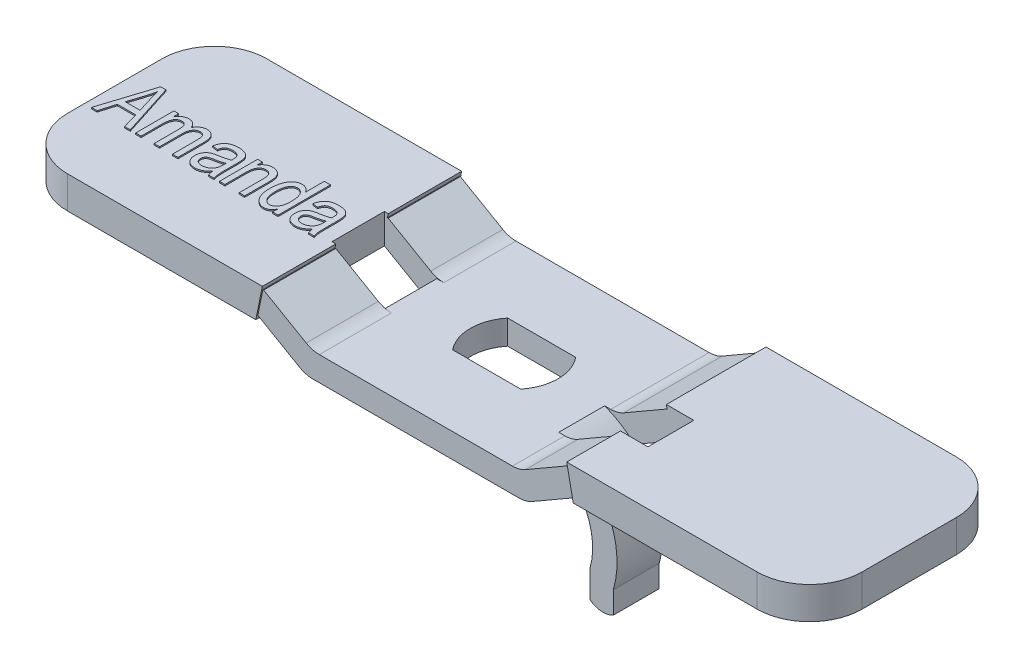
from build123d import *

# Parameters (mm, degrees)
BOSS_EXTRUDE1_DEPTH = 9.525
FILLET1_R           = 5.08
BOSS_EXTRUDE2_DEPTH = 9.652
SKETCH2_W           = 5.08
SKETCH2_H           = 5.08
SKETCH2_W_2         = 8.636
SKETCH2_H_2         = 4.445
CUT_EXTRUDE1_DEPTH  = 19.05
FILLET2_R           = 5.08
BOSS_EXTRUDE3_DEPTH = 4.445
FILLET3_R           = 2.54
BOSS_EXTRUDE4_DEPTH = 0.127


with BuildPart() as part:
    # Sketch1 → Boss-Extrude1 (new body, symmetric)
    with BuildSketch(Plane.XY):
        Polygon((15.375367685, 2.7178), (37.888728983, 2.7178), (37.888728983, 5.08), (14.742418102, 5.08), (10.035050418, 2.3622), (-10.035050418, 2.3622), (-14.742418102, 5.08), (-38.311271017, 5.08), (-38.311271017, 2.7178), (-15.375367685, 2.7178), (-10.668, 0), (10.668, 0), align=None)
    extrude(amount=BOSS_EXTRUDE1_DEPTH, both=True)

    # Fillet1
    fillet1_edges = [part.edges().sort_by_distance(p)[0] for p in [
        (37.888728983, 3.8989, 9.525),
        (-38.311271017, 3.8989, -9.525),
        (37.888728983, 3.8989, -9.525),
        (-38.311271017, 3.8989, 9.525),
    ]]
    fillet(fillet1_edges, radius=FILLET1_R)

    # Sketch3 → Boss-Extrude2 (add, symmetric)
    with BuildSketch(Plane.XY):
        Polygon((-38.692271017, 5.461), (-14.742418102, 5.461), (-15.375367685, 2.3368), (-38.692271017, 2.3368), align=None)
        Polygon((15.375367685, 2.3368), (38.269728983, 2.3368), (38.269728983, 5.461), (14.742418102, 5.461), align=None)
    extrude(amount=BOSS_EXTRUDE2_DEPTH, both=True)

    # Sketch2 → Cut-Extrude1 (cut)
    with BuildSketch(Plane(origin=(0, 0, 0), x_dir=(1, 0, 0), z_dir=(0, 1, 0))):
        with Locations((-12.575050418, 0)):
            Rectangle(SKETCH2_W, SKETCH2_H)
        with Locations((13.083050418, -2.2225)):
            Rectangle(SKETCH2_W_2, SKETCH2_H_2)
        with BuildLine():
            Line((3.298481202, -2.667), (-3.298481202, -2.667))
            ThreePointArc((-3.298481202, -2.667), (-4.2418, 0), (-3.298481202, 2.667))
            Line((-3.298481202, 2.667), (3.298481202, 2.667))
            ThreePointArc((3.298481202, 2.667), (4.2418, 0), (3.298481202, -2.667))
        make_face()
    extrude(amount=CUT_EXTRUDE1_DEPTH, mode=Mode.SUBTRACT)

    # Fillet2
    fillet2_edges = [part.edges().sort_by_distance(p)[0] for p in [
        (38.269728983, 3.8989, -9.652),
        (38.269728983, 3.8989, 9.652),
        (-38.692271017, 3.8989, -9.652),
        (-38.692271017, 3.8989, 9.652),
    ]]
    fillet(fillet2_edges, radius=FILLET2_R)

    # Sketch4 → Boss-Extrude3 (add)
    with BuildSketch(Plane.XY):
        with BuildLine():
            Line((8.765050418, 2.3622), (8.765050418, 0))
            ThreePointArc((8.765050418, 0), (11.584407716, -3.265765814), (11.774115705, -7.575987711))
            Line((11.774115705, -7.575987711), (11.774115705, -10.161057305))
            ThreePointArc((11.774115705, -10.161057305), (12.886519507, -10.585606292), (14.051112182, -10.3378))
            Line((14.051112182, -10.3378), (14.051112182, -8.204697409))
            ThreePointArc((14.051112182, -8.204697409), (13.496081615, -1.876732211), (8.765050418, 2.3622))
        make_face()
    extrude(amount=BOSS_EXTRUDE3_DEPTH)

    # Fillet3
    fillet3_edges = [part.edges().sort_by_distance(p)[0] for p in [
        (10.668, 0, 6.985),
        (10.668, 0, -4.7625),
        (-10.668, 0, 6.0325),
        (-10.035050418, 2.3622, -6.0325),
        (10.035050418, 2.3622, 6.985),
        (10.035050418, 2.3622, -4.7625),
        (-10.035050418, 2.3622, 6.0325),
    ]]
    fillet(fillet3_edges, radius=FILLET3_R)

    # Sketch5 → Boss-Extrude4 (add)
    with BuildSketch(Plane(origin=(0, 5.461, 0), x_dir=(1, 0, 0), z_dir=(0, 1, 0))):
        Polygon((-37.905243778, -3.048), (-36.282695077, 2.032), (-35.768303843, 2.032), (-34.144724298, -3.048), (-34.693133389, -3.048), (-35.13742722, -1.530597403), (-36.912540856, -1.530597403), (-37.355803843, -3.048), align=None)
        with BuildLine():
            Line((-36.739359038, -0.936831169), (-35.311639882, -0.936831169))
            Line((-35.311639882, -0.936831169), (-35.736347674, 0.458931818))
            add(Edge.make_bspline(
                [(-35.736347674, 0.458931818), (-35.752236099, 0.511136876), (-35.783255933, 0.613059641), (-35.827182846, 0.762305939), (-35.869342701, 0.903863262), (-35.905355341, 1.038719049), (-35.941165615, 1.165118694), (-35.972049539, 1.284468818), (-35.999773008, 1.396177097), (-36.016803166, 1.468455951), (-36.024984038, 1.503176948)],
                knots=[0, 0, 0, 0, 0.000163706, 0.000319613, 0.000466735, 0.000606782, 0.000738331, 0.000860845, 0.000976603, 0.001083617, 0.001083617, 0.001083617, 0.001083617], degree=3))
            add(Edge.make_bspline(
                [(-36.024984038, 1.503176948), (-36.039835852, 1.422302291), (-36.069519751, 1.260660411), (-36.12516105, 1.019864869), (-36.187063684, 0.779503851), (-36.236335898, 0.620929172), (-36.26104735, 0.541399351)],
                knots=[0, 0, 0, 0, 0.00024665, 0.000492972, 0.000741253, 0.000991058, 0.000991058, 0.000991058, 0.000991058], degree=3))
            Line((-36.26104735, 0.541399351), (-36.739359038, -0.936831169))
        make_face(mode=Mode.SUBTRACT)
        with BuildLine():
            Line((-33.61693209, -3.048), (-33.61693209, 0.646545455))
            Line((-33.61693209, 0.646545455), (-33.155113908, 0.646545455))
            Line((-33.155113908, 0.646545455), (-33.155113908, 0.125969156))
            add(Edge.make_bspline(
                [(-33.155113908, 0.125969156), (-33.129105702, 0.171044772), (-33.078259634, 0.259167647), (-32.984275697, 0.376165428), (-32.880376363, 0.477269279), (-32.76670311, 0.562434272), (-32.64419807, 0.629636863), (-32.51490498, 0.677154815), (-32.380309915, 0.707695375), (-32.288338634, 0.710898281), (-32.241785986, 0.712519481)],
                knots=[0, 0, 0, 0, 0.000155934, 0.000304851, 0.000448464, 0.000589896, 0.000729674, 0.00086601, 0.001002086, 0.001141558, 0.001141558, 0.001141558, 0.001141558], degree=3))
            add(Edge.make_bspline(
                [(-32.241785986, 0.712519481), (-32.190426095, 0.710627182), (-32.091241039, 0.706972818), (-31.948525295, 0.676302597), (-31.818051742, 0.626104499), (-31.70142339, 0.55357165), (-31.597990027, 0.463205), (-31.510597164, 0.353221481), (-31.439470499, 0.224483046), (-31.407070101, 0.129663896), (-31.390308713, 0.080612013)],
                knots=[0, 0, 0, 0, 0.000153941, 0.000297288, 0.00043569, 0.000571296, 0.000707156, 0.00084577, 0.00099065, 0.001145928, 0.001145928, 0.001145928, 0.001145928], degree=3))
            add(Edge.make_bspline(
                [(-31.390308713, 0.080612013), (-31.360014596, 0.13073863), (-31.301582224, 0.227424636), (-31.201241271, 0.356953549), (-31.094454655, 0.466847023), (-30.980255747, 0.55676612), (-30.858884972, 0.626204561), (-30.731416497, 0.677018367), (-30.596840897, 0.70621142), (-30.504949649, 0.71039922), (-30.458425596, 0.712519481)],
                knots=[0, 0, 0, 0, 0.000175598, 0.000338699, 0.000490321, 0.000634256, 0.00077324, 0.000908387, 0.001044462, 0.001184008, 0.001184008, 0.001184008, 0.001184008], degree=3))
            add(Edge.make_bspline(
                [(-30.458425596, 0.712519481), (-30.423318685, 0.71195128), (-30.354505755, 0.710837551), (-30.254479256, 0.695561566), (-30.159784894, 0.673107858), (-30.070609794, 0.641838298), (-29.988593819, 0.598008296), (-29.910727007, 0.548097879), (-29.839251646, 0.487619294), (-29.773723509, 0.417898488), (-29.714711531, 0.338319079), (-29.66375548, 0.247611044), (-29.622267259, 0.145401317), (-29.585558042, 0.033409941), (-29.559741963, -0.090452669), (-29.53995959, -0.224660825), (-29.529014581, -0.370374537), (-29.527386163, -0.471216441), (-29.526542479, -0.523462662)],
                knots=[0, 0, 0, 0, 0.000105227, 0.000206255, 0.000302764, 0.000397, 0.000488751, 0.000581103, 0.000674022, 0.000768826, 0.000867582, 0.000970512, 0.00108002, 0.001198032, 0.001323596, 0.00145903, 0.001604821, 0.001761563, 0.001761563, 0.001761563, 0.001761563], degree=3))
            Line((-29.526542479, -0.523462662), (-29.526542479, -3.048))
            Line((-29.526542479, -3.048), (-30.054334687, -3.048))
            Line((-30.054334687, -3.048), (-30.054334687, -0.722415584))
            add(Edge.make_bspline(
                [(-30.054334687, -0.722415584), (-30.054579593, -0.661223159), (-30.055031405, -0.548332954), (-30.066687032, -0.393509892), (-30.082422932, -0.267005804), (-30.107351812, -0.165845484), (-30.140532221, -0.083657025), (-30.181700634, -0.013646077), (-30.23311364, 0.04590908), (-30.292367263, 0.095268339), (-30.35655009, 0.135837826), (-30.426485605, 0.16377399), (-30.499715265, 0.182367995), (-30.550399599, 0.183936719), (-30.57594183, 0.184727273)],
                knots=[0, 0, 0, 0, 0.000183516, 0.000338558, 0.000465536, 0.000565544, 0.000650155, 0.000730594, 0.000808079, 0.000884896, 0.000961276, 0.001034784, 0.001110043, 0.001186499, 0.001186499, 0.001186499, 0.001186499], degree=3))
            add(Edge.make_bspline(
                [(-30.57594183, 0.184727273), (-30.602109688, 0.183967741), (-30.65371459, 0.182469889), (-30.72943055, 0.169590906), (-30.801624099, 0.149498916), (-30.869833741, 0.119614581), (-30.934347589, 0.082977712), (-30.995421017, 0.037784347), (-31.051807036, -0.016439202), (-31.105786891, -0.077727804), (-31.153228667, -0.149058535), (-31.196109064, -0.228699461), (-31.23053878, -0.318577528), (-31.258120613, -0.417797325), (-31.280596789, -0.525565966), (-31.297246619, -0.642939506), (-31.306125255, -0.769694217), (-31.307256353, -0.857443167), (-31.307841181, -0.902813312)],
                knots=[0, 0, 0, 0, 7.8453e-05, 0.000154714, 0.000229761, 0.000302718, 0.000377516, 0.000451944, 0.000529969, 0.000611816, 0.000696446, 0.000786372, 0.00088266, 0.000984469, 0.001095058, 0.001212705, 0.001339838, 0.001475945, 0.001475945, 0.001475945, 0.001475945], degree=3))
            Line((-31.307841181, -0.902813312), (-31.307841181, -3.048))
            Line((-31.307841181, -3.048), (-31.835633389, -3.048))
            Line((-31.835633389, -3.048), (-31.835633389, -0.649225649))
            add(Edge.make_bspline(
                [(-31.835633389, -0.649225649), (-31.83603731, -0.612454267), (-31.836815574, -0.541604292), (-31.842497715, -0.439333436), (-31.854312137, -0.345883479), (-31.868030271, -0.260249401), (-31.887539642, -0.183404411), (-31.910855301, -0.114876659), (-31.939086428, -0.055168747), (-31.980510564, 0.012403491), (-32.043668244, 0.081501021), (-32.133850325, 0.142647121), (-32.238440879, 0.179191148), (-32.312619838, 0.18283778), (-32.351055466, 0.184727273)],
                knots=[0, 0, 0, 0, 0.00011032, 0.00021256, 0.00030705, 0.000392802, 0.000472558, 0.000544607, 0.000609623, 0.000670268, 0.000781909, 0.000887408, 0.000994338, 0.001109323, 0.001109323, 0.001109323, 0.001109323], degree=3))
            add(Edge.make_bspline(
                [(-32.351055466, 0.184727273), (-32.378946978, 0.184063015), (-32.433356079, 0.182767219), (-32.512668272, 0.168888645), (-32.587124571, 0.146335507), (-32.657044033, 0.114544575), (-32.723897185, 0.075941647), (-32.784481905, 0.025294907), (-32.84145081, -0.032436781), (-32.89420082, -0.099671922), (-32.940996374, -0.179163731), (-32.980781768, -0.272839361), (-33.014447204, -0.38063453), (-33.042015964, -0.503039945), (-33.063097036, -0.639802389), (-33.078347288, -0.791195265), (-33.087538569, -0.956990142), (-33.088591731, -1.072546637), (-33.089139882, -1.132691558)],
                knots=[0, 0, 0, 0, 8.36e-05, 0.000163082, 0.00024069, 0.000316364, 0.000393091, 0.000471497, 0.00055241, 0.00063613, 0.000727178, 0.00082829, 0.000940766, 0.001065549, 0.00120435, 0.001355645, 0.00152187, 0.001702294, 0.001702294, 0.001702294, 0.001702294], degree=3))
            Line((-33.089139882, -1.132691558), (-33.089139882, -3.048))
            Line((-33.089139882, -3.048), (-33.61693209, -3.048))
        make_face()
        with BuildLine():
            add(Edge.make_bspline(
                [(-26.689659363, -2.538762987), (-26.732935088, -2.584154506), (-26.817068903, -2.672401706), (-26.951834425, -2.789493335), (-27.089278233, -2.889210566), (-27.229581229, -2.971333075), (-27.37286375, -3.034638826), (-27.518215515, -3.080784808), (-27.666882841, -3.108394635), (-27.767122658, -3.112110268), (-27.817402869, -3.113974026)],
                knots=[0, 0, 0, 0, 0.000188066, 0.000365626, 0.000534713, 0.000696844, 0.000852378, 0.001003656, 0.001153484, 0.001304273, 0.001304273, 0.001304273, 0.001304273], degree=3))
            add(Edge.make_bspline(
                [(-27.817402869, -3.113974026), (-27.856279769, -3.113337128), (-27.9322168, -3.112093095), (-28.043144043, -3.097839946), (-28.148342792, -3.077184624), (-28.247116387, -3.045398488), (-28.340480754, -3.00674966), (-28.42723735, -2.95773832), (-28.508523209, -2.900938285), (-28.582327772, -2.834703488), (-28.649574589, -2.761937459), (-28.707472871, -2.681700037), (-28.757367123, -2.595936562), (-28.797744113, -2.503568712), (-28.828221913, -2.405223529), (-28.851326871, -2.301187667), (-28.8647225, -2.191034793), (-28.866100032, -2.115465696), (-28.86680222, -2.076944805)],
                knots=[0, 0, 0, 0, 0.000116558, 0.00022767, 0.000335021, 0.000437718, 0.000538425, 0.000637649, 0.000736034, 0.000835338, 0.000934567, 0.001032714, 0.001131551, 0.001231718, 0.001334415, 0.001439965, 0.001551076, 0.001666605, 0.001666605, 0.001666605, 0.001666605], degree=3))
            add(Edge.make_bspline(
                [(-28.86680222, -2.076944805), (-28.865436381, -2.025618963), (-28.862777788, -1.925713666), (-28.835712256, -1.78072241), (-28.79408187, -1.644465587), (-28.733592487, -1.518170599), (-28.658772253, -1.403339607), (-28.570987936, -1.300445065), (-28.470291832, -1.211459128), (-28.375947682, -1.148055151), (-28.292093843, -1.104081559), (-28.220951506, -1.073546591), (-28.142444528, -1.044834427), (-28.056616461, -1.017677445), (-27.962785964, -0.994621031), (-27.861398211, -0.9728324), (-27.752384745, -0.953372641), (-27.676898419, -0.942452934), (-27.638035986, -0.936831169)],
                knots=[0, 0, 0, 0, 0.000153817, 0.000299403, 0.000440903, 0.000580155, 0.000717969, 0.000851023, 0.000984656, 0.001119889, 0.001190898, 0.001268458, 0.00135195, 0.00144161, 0.001538367, 0.001641683, 0.001752694, 0.00187049, 0.00187049, 0.00187049, 0.00187049], degree=3))
            add(Edge.make_bspline(
                [(-27.638035986, -0.936831169), (-27.585745319, -0.927878137), (-27.484696117, -0.910576833), (-27.339449384, -0.880275938), (-27.204535355, -0.849694415), (-27.08098856, -0.816614824), (-26.967222381, -0.783928019), (-26.864856971, -0.748875624), (-26.772396979, -0.713705109), (-26.716282178, -0.686053806), (-26.689659363, -0.672935065)],
                knots=[0, 0, 0, 0, 0.000159141, 0.000307533, 0.000445064, 0.000574085, 0.000691189, 0.000800069, 0.000898653, 0.000987647, 0.000987647, 0.000987647, 0.000987647], degree=3))
            Line((-26.689659363, -0.672935065), (-26.689659363, -0.522431818))
            add(Edge.make_bspline(
                [(-26.689659363, -0.522431818), (-26.689879796, -0.493887582), (-26.690302868, -0.439103441), (-26.698361258, -0.360394835), (-26.707850331, -0.28788318), (-26.722931571, -0.221769193), (-26.744155325, -0.162817288), (-26.767403267, -0.109409506), (-26.795951111, -0.062603806), (-26.819494203, -0.036252668), (-26.830885012, -0.023503247)],
                knots=[0, 0, 0, 0, 8.5585e-05, 0.000164261, 0.000237152, 0.000304914, 0.000367184, 0.000424856, 0.000479491, 0.000530702, 0.000530702, 0.000530702, 0.000530702], degree=3))
            add(Edge.make_bspline(
                [(-26.830885012, -0.023503247), (-26.847986806, -0.006858294), (-26.88260318, 0.026833372), (-26.943348697, 0.068957812), (-27.010572585, 0.104911901), (-27.084047374, 0.134975886), (-27.164244208, 0.157833215), (-27.251421671, 0.172322678), (-27.344993572, 0.183472061), (-27.409838619, 0.184300815), (-27.44320644, 0.184727273)],
                knots=[0, 0, 0, 0, 7.1493e-05, 0.000144712, 0.000220813, 0.000299873, 0.000382424, 0.000470385, 0.000564757, 0.000664796, 0.000664796, 0.000664796, 0.000664796], degree=3))
            add(Edge.make_bspline(
                [(-27.44320644, 0.184727273), (-27.501760839, 0.183637508), (-27.61133784, 0.181598154), (-27.764206408, 0.154065892), (-27.894810726, 0.112672212), (-27.986987434, 0.060112571), (-28.048111568, 0.007294884), (-28.090214258, -0.038906819), (-28.128361967, -0.093248826), (-28.163414164, -0.15487301), (-28.196560069, -0.22349137), (-28.224801768, -0.300820454), (-28.252173241, -0.384782468), (-28.265935736, -0.444304697), (-28.273035986, -0.475012987)],
                knots=[0, 0, 0, 0, 0.000175437, 0.000328309, 0.000464243, 0.000584821, 0.000643298, 0.000706053, 0.000771841, 0.000842037, 0.000918577, 0.001000138, 0.001088814, 0.001183321, 0.001183321, 0.001183321, 0.001183321], degree=3))
            Line((-28.273035986, -0.475012987), (-28.800828194, -0.409038961))
            add(Edge.make_bspline(
                [(-28.800828194, -0.409038961), (-28.790702715, -0.361841999), (-28.770972446, -0.26987511), (-28.733372686, -0.137500567), (-28.686569177, -0.015341525), (-28.633499895, 0.096921169), (-28.573098354, 0.199032532), (-28.506379368, 0.291734675), (-28.430308226, 0.373009453), (-28.348454451, 0.446380666), (-28.257394715, 0.509899904), (-28.15744808, 0.564420267), (-28.047905593, 0.609437136), (-27.93031606, 0.648202662), (-27.802703393, 0.676033233), (-27.666527299, 0.698216108), (-27.52073551, 0.710217766), (-27.420547539, 0.711737399), (-27.368985661, 0.712519481)],
                knots=[0, 0, 0, 0, 0.000144796, 0.000282146, 0.000412331, 0.000536824, 0.000654214, 0.000767822, 0.000878703, 0.00098751, 0.001097042, 0.001210986, 0.001328344, 0.001451895, 0.001581933, 0.001719715, 0.00186559, 0.002020271, 0.002020271, 0.002020271, 0.002020271], degree=3))
            add(Edge.make_bspline(
                [(-27.368985661, 0.712519481), (-27.328766713, 0.711894976), (-27.250647667, 0.710681973), (-27.136777077, 0.702190372), (-27.02962269, 0.689333864), (-26.928950774, 0.669889567), (-26.835271411, 0.643561792), (-26.747213908, 0.614485712), (-26.666286378, 0.578398799), (-26.570692243, 0.522490169), (-26.465559129, 0.444823614), (-26.35995956, 0.339855924), (-26.282663921, 0.221255039), (-26.240158504, 0.113374394), (-26.21754076, 0.020520352), (-26.201903703, -0.056450126), (-26.189974043, -0.141528287), (-26.179716632, -0.234004451), (-26.171657128, -0.334046261), (-26.165223609, -0.441262635), (-26.162490177, -0.556091474), (-26.162079567, -0.635136762), (-26.161867155, -0.676027597)],
                knots=[0, 0, 0, 0, 0.000120648, 0.000234341, 0.000342383, 0.000444275, 0.000541557, 0.000634138, 0.000722268, 0.000806785, 0.000965949, 0.001113198, 0.001251011, 0.001387496, 0.001458751, 0.001537595, 0.001623025, 0.001716372, 0.001816703, 0.001924089, 0.002038555, 0.002161229, 0.002161229, 0.002161229, 0.002161229], degree=3))
            Line((-26.161867155, -0.676027597), (-26.161867155, -1.506887987))
            add(Edge.make_bspline(
                [(-26.161867155, -1.506887987), (-26.16209037, -1.576299566), (-26.162514711, -1.708254065), (-26.159671789, -1.896201409), (-26.158316703, -2.063904064), (-26.154559523, -2.211636157), (-26.152565378, -2.339184743), (-26.146720828, -2.446345831), (-26.14222873, -2.533363578), (-26.130647477, -2.659949995), (-26.099828071, -2.831767539), (-26.053212491, -2.975952211), (-26.029919103, -3.048)],
                knots=[0, 0, 0, 0, 0.000208231, 0.000395855, 0.000563896, 0.000711339, 0.000839201, 0.000946533, 0.001033277, 0.001100566, 0.001327844, 0.00155484, 0.00155484, 0.00155484, 0.00155484], degree=3))
            Line((-26.029919103, -3.048), (-26.557711311, -3.048))
            add(Edge.make_bspline(
                [(-26.557711311, -3.048), (-26.573958402, -3.010838965), (-26.607202867, -2.934800818), (-26.643391279, -2.811471612), (-26.672748326, -2.678921622), (-26.68392216, -2.586312914), (-26.689659363, -2.538762987)],
                knots=[0, 0, 0, 0, 0.000121561, 0.000248736, 0.000384811, 0.000528409, 0.000528409, 0.000528409, 0.000528409], degree=3))
        make_face()
        with BuildLine():
            add(Edge.make_bspline(
                [(-26.689659363, -1.200727273), (-26.71600177, -1.213689875), (-26.770808367, -1.24065917), (-26.858790368, -1.277746873), (-26.955840065, -1.312776683), (-27.06251933, -1.34504688), (-27.177664401, -1.37860434), (-27.302248341, -1.409071815), (-27.435687137, -1.437930415), (-27.527696444, -1.455540277), (-27.575154492, -1.464623377)],
                knots=[0, 0, 0, 0, 8.8063e-05, 0.00018322, 0.000286263, 0.000397446, 0.000517521, 0.000646029, 0.000782105, 0.000927058, 0.000927058, 0.000927058, 0.000927058], degree=3))
            add(Edge.make_bspline(
                [(-27.575154492, -1.464623377), (-27.62778814, -1.473189057), (-27.724788088, -1.488974977), (-27.857646573, -1.515907959), (-27.964538625, -1.546130041), (-28.049310734, -1.578459353), (-28.116699925, -1.61645288), (-28.17397368, -1.660117272), (-28.224076186, -1.710834757), (-28.26508293, -1.768984702), (-28.298279981, -1.8319636), (-28.322604926, -1.899863251), (-28.335613156, -1.972679396), (-28.337862399, -2.022607009), (-28.339010012, -2.048081169)],
                knots=[0, 0, 0, 0, 0.00015998, 0.000294832, 0.000406411, 0.000492934, 0.000566327, 0.000637664, 0.000708373, 0.000779314, 0.000850323, 0.000921399, 0.000994792, 0.001071248, 0.001071248, 0.001071248, 0.001071248], degree=3))
            add(Edge.make_bspline(
                [(-28.339010012, -2.048081169), (-28.337469715, -2.087212609), (-28.334503804, -2.162561928), (-28.299004164, -2.268792232), (-28.245362745, -2.363718413), (-28.168117685, -2.44396017), (-28.072236454, -2.508401472), (-27.958275753, -2.553328325), (-27.828745065, -2.581678956), (-27.73681482, -2.584631566), (-27.68854735, -2.586181818)],
                knots=[0, 0, 0, 0, 0.000116941, 0.000225174, 0.000332323, 0.000441699, 0.000556062, 0.000676278, 0.000807098, 0.000951714, 0.000951714, 0.000951714, 0.000951714], degree=3))
            add(Edge.make_bspline(
                [(-27.68854735, -2.586181818), (-27.641340715, -2.584755889), (-27.54825841, -2.581944232), (-27.412201777, -2.554832226), (-27.282178119, -2.513074966), (-27.160906013, -2.452775365), (-27.049929297, -2.379498313), (-26.95288152, -2.292881372), (-26.870474605, -2.195304109), (-26.814707582, -2.103744102), (-26.77784258, -2.023481822), (-26.754121134, -1.956173151), (-26.735377923, -1.88245221), (-26.716731432, -1.80303555), (-26.70558532, -1.716325078), (-26.695810433, -1.62356695), (-26.691062972, -1.524116038), (-26.6901379, -1.455692404), (-26.689659363, -1.420297078)],
                knots=[0, 0, 0, 0, 0.000141466, 0.000278944, 0.000414554, 0.000550093, 0.000683897, 0.000812393, 0.000938969, 0.001065729, 0.001132615, 0.001203691, 0.001279456, 0.001360742, 0.001448212, 0.001541451, 0.001640546, 0.001746743, 0.001746743, 0.001746743, 0.001746743], degree=3))
            Line((-26.689659363, -1.420297078), (-26.689659363, -1.200727273))
        make_face(mode=Mode.SUBTRACT)
        with BuildLine():
            Line((-25.502126895, -3.048), (-25.502126895, 0.646545455))
            Line((-25.502126895, 0.646545455), (-25.040308713, 0.646545455))
            Line((-25.040308713, 0.646545455), (-25.040308713, 0.118753247))
            add(Edge.make_bspline(
                [(-25.040308713, 0.118753247), (-25.012176801, 0.166193633), (-24.957828222, 0.257844621), (-24.860827599, 0.380159708), (-24.754149305, 0.482857715), (-24.638626437, 0.567665962), (-24.513768137, 0.633739659), (-24.378867863, 0.678576871), (-24.235766901, 0.707561007), (-24.137089871, 0.710845057), (-24.086777869, 0.712519481)],
                knots=[0, 0, 0, 0, 0.000165324, 0.000319393, 0.000466663, 0.000608314, 0.000748026, 0.000888528, 0.001033481, 0.00118427, 0.00118427, 0.00118427, 0.00118427], degree=3))
            add(Edge.make_bspline(
                [(-24.086777869, 0.712519481), (-24.047196521, 0.711291431), (-23.969357323, 0.708876395), (-23.854876466, 0.690923932), (-23.745092552, 0.661280902), (-23.641187979, 0.618478228), (-23.544445832, 0.567407574), (-23.454977297, 0.510038128), (-23.378136163, 0.441980589), (-23.308353844, 0.368423086), (-23.249236224, 0.284038915), (-23.196869028, 0.189822441), (-23.155693778, 0.082544164), (-23.126488817, -0.014377293), (-23.107192165, -0.100437931), (-23.095712254, -0.174231533), (-23.083435105, -0.256199976), (-23.076457789, -0.3464705), (-23.06825709, -0.444653334), (-23.065172093, -0.551288763), (-23.06151373, -0.666038225), (-23.06123269, -0.745433656), (-23.061087934, -0.786327922)],
                knots=[0, 0, 0, 0, 0.000118708, 0.000233447, 0.000346732, 0.000459099, 0.000569765, 0.000674694, 0.000777002, 0.00087693, 0.000978189, 0.001085223, 0.001199503, 0.001322134, 0.001388662, 0.001463906, 0.001546129, 0.001637217, 0.001735413, 0.00184167, 0.001957166, 0.002079841, 0.002079841, 0.002079841, 0.002079841], degree=3))
            Line((-23.061087934, -0.786327922), (-23.061087934, -3.048))
            Line((-23.061087934, -3.048), (-23.588880142, -3.048))
            Line((-23.588880142, -3.048), (-23.588880142, -0.802821429))
            add(Edge.make_bspline(
                [(-23.588880142, -0.802821429), (-23.589598517, -0.739581199), (-23.590935389, -0.621893326), (-23.602247007, -0.458835054), (-23.623362, -0.323291985), (-23.651705958, -0.211725565), (-23.691240621, -0.120120912), (-23.738945953, -0.041193796), (-23.797398393, 0.026454315), (-23.864686694, 0.083214472), (-23.938847825, 0.129067324), (-24.019816485, 0.161165539), (-24.106033865, 0.181629443), (-24.165692126, 0.183682593), (-24.19604735, 0.184727273)],
                knots=[0, 0, 0, 0, 0.00018972, 0.000353063, 0.000489827, 0.000600853, 0.000697362, 0.000788059, 0.000876501, 0.000964274, 0.001051257, 0.001136823, 0.001224597, 0.001315521, 0.001315521, 0.001315521, 0.001315521], degree=3))
            add(Edge.make_bspline(
                [(-24.19604735, 0.184727273), (-24.224968494, 0.184057944), (-24.281763296, 0.182743529), (-24.364364238, 0.168803976), (-24.442544967, 0.147196328), (-24.516161371, 0.116979855), (-24.585944927, 0.07905687), (-24.649968599, 0.030645839), (-24.710452893, -0.025049468), (-24.765032901, -0.090801221), (-24.815835124, -0.166071813), (-24.858458573, -0.254013103), (-24.894307398, -0.354020946), (-24.924217024, -0.465685492), (-24.946238169, -0.589902693), (-24.962416659, -0.726195357), (-24.973028321, -0.874813948), (-24.973888086, -0.978045595), (-24.974334687, -1.031668831)],
                knots=[0, 0, 0, 0, 8.6689e-05, 0.000170238, 0.000250525, 0.000329585, 0.000408483, 0.000488065, 0.000569756, 0.000654624, 0.000743826, 0.000841561, 0.000946894, 0.001062169, 0.001187932, 0.001324999, 0.001473798, 0.00163464, 0.00163464, 0.00163464, 0.00163464], degree=3))
            Line((-24.974334687, -1.031668831), (-24.974334687, -3.048))
            Line((-24.974334687, -3.048), (-25.502126895, -3.048))
        make_face()
        with BuildLine():
            Line((-20.356152869, -3.048), (-20.356152869, -2.552163961))
            add(Edge.make_bspline(
                [(-20.356152869, -2.552163961), (-20.379427563, -2.595811064), (-20.424688943, -2.680689864), (-20.509674202, -2.793521255), (-20.602430609, -2.892064269), (-20.705828707, -2.972170174), (-20.815271734, -3.03586178), (-20.930405373, -3.080609115), (-21.049958274, -3.108513093), (-21.131542291, -3.112146377), (-21.17258144, -3.113974026)],
                knots=[0, 0, 0, 0, 0.000148191, 0.000288181, 0.000422333, 0.000553068, 0.000679139, 0.000800887, 0.000922427, 0.001045447, 0.001045447, 0.001045447, 0.001045447], degree=3))
            add(Edge.make_bspline(
                [(-21.17258144, -3.113974026), (-21.215626014, -3.112240916), (-21.30093438, -3.108806133), (-21.426883509, -3.085768049), (-21.548580242, -3.046299307), (-21.665178856, -2.989940511), (-21.77757727, -2.919091026), (-21.885490795, -2.832710475), (-21.988345157, -2.730080641), (-22.086198023, -2.612793542), (-22.175564877, -2.481086553), (-22.254529544, -2.335969807), (-22.319889361, -2.17737842), (-22.374742575, -2.006830467), (-22.416807349, -1.823342193), (-22.446234213, -1.62726097), (-22.463766578, -1.418211834), (-22.466113498, -1.274639033), (-22.4673217, -1.200727273)],
                knots=[0, 0, 0, 0, 0.000129119, 0.000255896, 0.000382707, 0.000511809, 0.00064337, 0.000780535, 0.000925591, 0.001078563, 0.001238104, 0.001402316, 0.001573278, 0.001751926, 0.001939217, 0.002137345, 0.002346312, 0.00256803, 0.00256803, 0.00256803, 0.00256803], degree=3))
            add(Edge.make_bspline(
                [(-22.4673217, -1.200727273), (-22.466548196, -1.149867461), (-22.465026577, -1.049817338), (-22.458386492, -0.902568381), (-22.444708557, -0.761259709), (-22.426370937, -0.626063943), (-22.402588918, -0.496731801), (-22.373929268, -0.373170849), (-22.340046501, -0.255415897), (-22.300670738, -0.144093723), (-22.257716664, -0.03896822), (-22.210174944, 0.059496859), (-22.158494227, 0.150601444), (-22.105565304, 0.235931689), (-22.047057817, 0.312743138), (-21.985091985, 0.382710358), (-21.920736377, 0.446990021), (-21.830030287, 0.520606975), (-21.710051671, 0.597175538), (-21.556070266, 0.664014502), (-21.393559446, 0.704854499), (-21.282426991, 0.709943866), (-21.226185337, 0.712519481)],
                knots=[0, 0, 0, 0, 0.000152596, 0.000300183, 0.000442044, 0.000578353, 0.000709372, 0.000836396, 0.000958737, 0.001076758, 0.001190469, 0.001299276, 0.001404508, 0.0015046, 0.001600264, 0.001693747, 0.001784865, 0.001872771, 0.002043782, 0.002210001, 0.002374513, 0.002543075, 0.002543075, 0.002543075, 0.002543075], degree=3))
            add(Edge.make_bspline(
                [(-21.226185337, 0.712519481), (-21.185846247, 0.711028079), (-21.105698044, 0.708064871), (-20.988104829, 0.681328952), (-20.875584094, 0.637240807), (-20.768168695, 0.577109501), (-20.667357654, 0.501875954), (-20.574789615, 0.412272), (-20.491664057, 0.308638138), (-20.445622359, 0.23137249), (-20.422126895, 0.191943182)],
                knots=[0, 0, 0, 0, 0.00012089, 0.000240192, 0.000359646, 0.000482399, 0.000608368, 0.000735948, 0.00086796, 0.001005531, 0.001005531, 0.001005531, 0.001005531], degree=3))
            Line((-20.422126895, 0.191943182), (-20.422126895, 2.032))
            Line((-20.422126895, 2.032), (-19.828360661, 2.032))
            Line((-19.828360661, 2.032), (-19.828360661, -3.048))
            Line((-19.828360661, -3.048), (-20.356152869, -3.048))
        make_face()
        with BuildLine():
            add(Edge.make_bspline(
                [(-21.939529492, -1.203819805), (-21.938719795, -1.260537547), (-21.937152677, -1.370311129), (-21.925692887, -1.528925658), (-21.907723612, -1.676397199), (-21.880829086, -1.81237579), (-21.84746267, -1.937822468), (-21.805038271, -2.051588411), (-21.755789293, -2.154389301), (-21.698957371, -2.2453316), (-21.636733689, -2.324821425), (-21.571769208, -2.394458867), (-21.504045802, -2.453298103), (-21.433713747, -2.501368605), (-21.36181946, -2.540832414), (-21.285414985, -2.56556415), (-21.207785098, -2.583632717), (-21.154819578, -2.585330373), (-21.128255142, -2.586181818)],
                knots=[0, 0, 0, 0, 0.000170139, 0.000329294, 0.000476845, 0.000615531, 0.000744819, 0.000865832, 0.000979248, 0.001086223, 0.00118685, 0.001281654, 0.001371551, 0.001455329, 0.001536948, 0.00161649, 0.001695543, 0.001775085, 0.001775085, 0.001775085, 0.001775085], degree=3))
            add(Edge.make_bspline(
                [(-21.128255142, -2.586181818), (-21.102063929, -2.585203945), (-21.049908232, -2.583256664), (-20.972910563, -2.567100127), (-20.898853353, -2.541342532), (-20.827122579, -2.505799468), (-20.759509413, -2.458473972), (-20.692584881, -2.402865524), (-20.630373536, -2.335179996), (-20.570327125, -2.258636211), (-20.513788384, -2.172327735), (-20.467679054, -2.07346536), (-20.425356547, -1.96579198), (-20.393302225, -1.846710426), (-20.367641411, -1.717561673), (-20.349055917, -1.578136481), (-20.339336052, -1.428339179), (-20.337509578, -1.325128478), (-20.33656683, -1.271855519)],
                knots=[0, 0, 0, 0, 7.8514e-05, 0.000156347, 0.000234915, 0.000313286, 0.000395631, 0.000481952, 0.000573842, 0.000670763, 0.000773703, 0.000882509, 0.000997373, 0.001120424, 0.001251832, 0.001392227, 0.001542055, 0.001701889, 0.001701889, 0.001701889, 0.001701889], degree=3))
            add(Edge.make_bspline(
                [(-20.33656683, -1.271855519), (-20.337502611, -1.210681037), (-20.339307201, -1.092710162), (-20.349011555, -0.92198624), (-20.367592149, -0.764034692), (-20.393033694, -0.618707897), (-20.42520804, -0.485981273), (-20.467088912, -0.367068161), (-20.513706153, -0.259589054), (-20.56969319, -0.165709492), (-20.631167814, -0.084026679), (-20.695157211, -0.011695662), (-20.763832537, 0.049248862), (-20.8370213, 0.098081285), (-20.913267185, 0.137205717), (-20.993745411, 0.164849442), (-21.078381048, 0.182145896), (-21.136074653, 0.183858028), (-21.165365531, 0.184727273)],
                knots=[0, 0, 0, 0, 0.000183537, 0.000353938, 0.000512745, 0.000660361, 0.00079637, 0.000921883, 0.001038168, 0.001147247, 0.001248889, 0.001344513, 0.001436542, 0.001523457, 0.001607823, 0.00169291, 0.001778021, 0.001865795, 0.001865795, 0.001865795, 0.001865795], degree=3))
            add(Edge.make_bspline(
                [(-21.165365531, 0.184727273), (-21.191548332, 0.183736464), (-21.243350452, 0.18177617), (-21.319626909, 0.166072008), (-21.391991466, 0.138500461), (-21.462434672, 0.102220009), (-21.529253849, 0.053825419), (-21.594904528, -0.003598542), (-21.654848156, -0.074014418), (-21.714535822, -0.152011304), (-21.76837049, -0.242310097), (-21.814296073, -0.344871505), (-21.853529378, -0.459083185), (-21.884974857, -0.585025625), (-21.909706461, -0.722788428), (-21.926402089, -0.872601732), (-21.938507161, -1.034220848), (-21.939181366, -1.146067582), (-21.939529492, -1.203819805)],
                knots=[0, 0, 0, 0, 7.8514e-05, 0.000155337, 0.000232313, 0.000310236, 0.000392322, 0.000479213, 0.000571242, 0.000669172, 0.000773654, 0.000885756, 0.001005724, 0.001135483, 0.0012748, 0.001425296, 0.001587535, 0.001760745, 0.001760745, 0.001760745, 0.001760745], degree=3))
        make_face(mode=Mode.SUBTRACT)
        with BuildLine():
            add(Edge.make_bspline(
                [(-16.991477544, -2.538762987), (-17.03475327, -2.584154506), (-17.118887085, -2.672401706), (-17.253652606, -2.789493335), (-17.391096415, -2.889210566), (-17.531399411, -2.971333075), (-17.674681932, -3.034638826), (-17.820033697, -3.080784808), (-17.968701023, -3.108394635), (-18.06894084, -3.112110268), (-18.119221051, -3.113974026)],
                knots=[0, 0, 0, 0, 0.000188066, 0.000365626, 0.000534713, 0.000696844, 0.000852378, 0.001003656, 0.001153484, 0.001304273, 0.001304273, 0.001304273, 0.001304273], degree=3))
            add(Edge.make_bspline(
                [(-18.119221051, -3.113974026), (-18.158097951, -3.113337128), (-18.234034982, -3.112093095), (-18.344962225, -3.097839946), (-18.450160974, -3.077184624), (-18.548934569, -3.045398488), (-18.642298935, -3.00674966), (-18.729055531, -2.95773832), (-18.810341391, -2.900938285), (-18.884145954, -2.834703488), (-18.951392771, -2.761937459), (-19.009291053, -2.681700037), (-19.059185305, -2.595936562), (-19.099562295, -2.503568712), (-19.130040094, -2.405223529), (-19.153145053, -2.301187667), (-19.166540682, -2.191034793), (-19.167918213, -2.115465696), (-19.168620402, -2.076944805)],
                knots=[0, 0, 0, 0, 0.000116558, 0.00022767, 0.000335021, 0.000437718, 0.000538425, 0.000637649, 0.000736034, 0.000835338, 0.000934567, 0.001032714, 0.001131551, 0.001231718, 0.001334415, 0.001439965, 0.001551076, 0.001666605, 0.001666605, 0.001666605, 0.001666605], degree=3))
            add(Edge.make_bspline(
                [(-19.168620402, -2.076944805), (-19.167254563, -2.025618963), (-19.16459597, -1.925713666), (-19.137530438, -1.78072241), (-19.095900052, -1.644465587), (-19.035410669, -1.518170599), (-18.960590434, -1.403339607), (-18.872806118, -1.300445065), (-18.772110014, -1.211459128), (-18.677765864, -1.148055151), (-18.593912025, -1.104081559), (-18.522769688, -1.073546591), (-18.44426271, -1.044834427), (-18.358434643, -1.017677445), (-18.264604146, -0.994621031), (-18.163216393, -0.9728324), (-18.054202926, -0.953372641), (-17.978716601, -0.942452934), (-17.939854168, -0.936831169)],
                knots=[0, 0, 0, 0, 0.000153817, 0.000299403, 0.000440903, 0.000580155, 0.000717969, 0.000851023, 0.000984656, 0.001119889, 0.001190898, 0.001268458, 0.00135195, 0.00144161, 0.001538367, 0.001641683, 0.001752694, 0.00187049, 0.00187049, 0.00187049, 0.00187049], degree=3))
            add(Edge.make_bspline(
                [(-17.939854168, -0.936831169), (-17.887563501, -0.927878137), (-17.786514299, -0.910576833), (-17.641267566, -0.880275938), (-17.506353537, -0.849694415), (-17.382806742, -0.816614824), (-17.269040563, -0.783928019), (-17.166675153, -0.748875624), (-17.074215161, -0.713705109), (-17.01810036, -0.686053806), (-16.991477544, -0.672935065)],
                knots=[0, 0, 0, 0, 0.000159141, 0.000307533, 0.000445064, 0.000574085, 0.000691189, 0.000800069, 0.000898653, 0.000987647, 0.000987647, 0.000987647, 0.000987647], degree=3))
            Line((-16.991477544, -0.672935065), (-16.991477544, -0.522431818))
            add(Edge.make_bspline(
                [(-16.991477544, -0.522431818), (-16.991697978, -0.493887582), (-16.99212105, -0.439103441), (-17.00017944, -0.360394835), (-17.009668513, -0.28788318), (-17.024749752, -0.221769193), (-17.045973507, -0.162817288), (-17.069221449, -0.109409506), (-17.097769292, -0.062603806), (-17.121312385, -0.036252668), (-17.132703194, -0.023503247)],
                knots=[0, 0, 0, 0, 8.5585e-05, 0.000164261, 0.000237152, 0.000304914, 0.000367184, 0.000424856, 0.000479491, 0.000530702, 0.000530702, 0.000530702, 0.000530702], degree=3))
            add(Edge.make_bspline(
                [(-17.132703194, -0.023503247), (-17.149804988, -0.006858294), (-17.184421362, 0.026833372), (-17.245166879, 0.068957812), (-17.312390767, 0.104911901), (-17.385865556, 0.134975886), (-17.46606239, 0.157833215), (-17.553239853, 0.172322678), (-17.646811754, 0.183472061), (-17.7116568, 0.184300815), (-17.745024622, 0.184727273)],
                knots=[0, 0, 0, 0, 7.1493e-05, 0.000144712, 0.000220813, 0.000299873, 0.000382424, 0.000470385, 0.000564757, 0.000664796, 0.000664796, 0.000664796, 0.000664796], degree=3))
            add(Edge.make_bspline(
                [(-17.745024622, 0.184727273), (-17.80357902, 0.183637508), (-17.913156022, 0.181598154), (-18.066024589, 0.154065892), (-18.196628908, 0.112672212), (-18.288805616, 0.060112571), (-18.34992975, 0.007294884), (-18.39203244, -0.038906819), (-18.430180148, -0.093248826), (-18.465232346, -0.15487301), (-18.49837825, -0.22349137), (-18.526619949, -0.300820454), (-18.553991423, -0.384782468), (-18.567753918, -0.444304697), (-18.574854168, -0.475012987)],
                knots=[0, 0, 0, 0, 0.000175437, 0.000328309, 0.000464243, 0.000584821, 0.000643298, 0.000706053, 0.000771841, 0.000842037, 0.000918577, 0.001000138, 0.001088814, 0.001183321, 0.001183321, 0.001183321, 0.001183321], degree=3))
            Line((-18.574854168, -0.475012987), (-19.102646376, -0.409038961))
            add(Edge.make_bspline(
                [(-19.102646376, -0.409038961), (-19.092520897, -0.361841999), (-19.072790628, -0.26987511), (-19.035190868, -0.137500567), (-18.988387359, -0.015341525), (-18.935318076, 0.096921169), (-18.874916536, 0.199032532), (-18.80819755, 0.291734675), (-18.732126408, 0.373009453), (-18.650272633, 0.446380666), (-18.559212897, 0.509899904), (-18.459266262, 0.564420267), (-18.349723775, 0.609437136), (-18.232134241, 0.648202662), (-18.104521575, 0.676033233), (-17.968345481, 0.698216108), (-17.822553692, 0.710217766), (-17.722365721, 0.711737399), (-17.670803843, 0.712519481)],
                knots=[0, 0, 0, 0, 0.000144796, 0.000282146, 0.000412331, 0.000536824, 0.000654214, 0.000767822, 0.000878703, 0.00098751, 0.001097042, 0.001210986, 0.001328344, 0.001451895, 0.001581933, 0.001719715, 0.00186559, 0.002020271, 0.002020271, 0.002020271, 0.002020271], degree=3))
            add(Edge.make_bspline(
                [(-17.670803843, 0.712519481), (-17.630584895, 0.711894976), (-17.552465849, 0.710681973), (-17.438595259, 0.702190372), (-17.331440872, 0.689333864), (-17.230768956, 0.669889567), (-17.137089593, 0.643561792), (-17.04903209, 0.614485712), (-16.96810456, 0.578398799), (-16.872510425, 0.522490169), (-16.767377311, 0.444823614), (-16.661777742, 0.339855924), (-16.584482103, 0.221255039), (-16.541976686, 0.113374394), (-16.519358942, 0.020520352), (-16.503721885, -0.056450126), (-16.491792225, -0.141528287), (-16.481534814, -0.234004451), (-16.47347531, -0.334046261), (-16.467041791, -0.441262635), (-16.464308359, -0.556091474), (-16.463897749, -0.635136762), (-16.463685337, -0.676027597)],
                knots=[0, 0, 0, 0, 0.000120648, 0.000234341, 0.000342383, 0.000444275, 0.000541557, 0.000634138, 0.000722268, 0.000806785, 0.000965949, 0.001113198, 0.001251011, 0.001387496, 0.001458751, 0.001537595, 0.001623025, 0.001716372, 0.001816703, 0.001924089, 0.002038555, 0.002161229, 0.002161229, 0.002161229, 0.002161229], degree=3))
            Line((-16.463685337, -0.676027597), (-16.463685337, -1.506887987))
            add(Edge.make_bspline(
                [(-16.463685337, -1.506887987), (-16.463908552, -1.576299566), (-16.464332893, -1.708254065), (-16.46148997, -1.896201409), (-16.460134885, -2.063904064), (-16.456377705, -2.211636157), (-16.45438356, -2.339184743), (-16.44853901, -2.446345831), (-16.444046912, -2.533363578), (-16.432465659, -2.659949995), (-16.401646252, -2.831767539), (-16.355030672, -2.975952211), (-16.331737285, -3.048)],
                knots=[0, 0, 0, 0, 0.000208231, 0.000395855, 0.000563896, 0.000711339, 0.000839201, 0.000946533, 0.001033277, 0.001100566, 0.001327844, 0.00155484, 0.00155484, 0.00155484, 0.00155484], degree=3))
            Line((-16.331737285, -3.048), (-16.859529492, -3.048))
            add(Edge.make_bspline(
                [(-16.859529492, -3.048), (-16.875776584, -3.010838965), (-16.909021049, -2.934800818), (-16.945209461, -2.811471612), (-16.974566508, -2.678921622), (-16.985740341, -2.586312914), (-16.991477544, -2.538762987)],
                knots=[0, 0, 0, 0, 0.000121561, 0.000248736, 0.000384811, 0.000528409, 0.000528409, 0.000528409, 0.000528409], degree=3))
        make_face()
        with BuildLine():
            add(Edge.make_bspline(
                [(-16.991477544, -1.200727273), (-17.017819952, -1.213689875), (-17.072626549, -1.24065917), (-17.16060855, -1.277746873), (-17.257658247, -1.312776683), (-17.364337512, -1.34504688), (-17.479482582, -1.37860434), (-17.604066523, -1.409071815), (-17.737505319, -1.437930415), (-17.829514626, -1.455540277), (-17.876972674, -1.464623377)],
                knots=[0, 0, 0, 0, 8.8063e-05, 0.00018322, 0.000286263, 0.000397446, 0.000517521, 0.000646029, 0.000782105, 0.000927058, 0.000927058, 0.000927058, 0.000927058], degree=3))
            add(Edge.make_bspline(
                [(-17.876972674, -1.464623377), (-17.929606322, -1.473189057), (-18.02660627, -1.488974977), (-18.159464755, -1.515907959), (-18.266356807, -1.546130041), (-18.351128916, -1.578459353), (-18.418518107, -1.61645288), (-18.475791862, -1.660117272), (-18.525894368, -1.710834757), (-18.566901111, -1.768984702), (-18.600098163, -1.8319636), (-18.624423108, -1.899863251), (-18.637431338, -1.972679396), (-18.639680581, -2.022607009), (-18.640828194, -2.048081169)],
                knots=[0, 0, 0, 0, 0.00015998, 0.000294832, 0.000406411, 0.000492934, 0.000566327, 0.000637664, 0.000708373, 0.000779314, 0.000850323, 0.000921399, 0.000994792, 0.001071248, 0.001071248, 0.001071248, 0.001071248], degree=3))
            add(Edge.make_bspline(
                [(-18.640828194, -2.048081169), (-18.639287897, -2.087212609), (-18.636321986, -2.162561928), (-18.600822346, -2.268792232), (-18.547180927, -2.363718413), (-18.469935867, -2.44396017), (-18.374054636, -2.508401472), (-18.260093935, -2.553328325), (-18.130563247, -2.581678956), (-18.038633002, -2.584631566), (-17.990365531, -2.586181818)],
                knots=[0, 0, 0, 0, 0.000116941, 0.000225174, 0.000332323, 0.000441699, 0.000556062, 0.000676278, 0.000807098, 0.000951714, 0.000951714, 0.000951714, 0.000951714], degree=3))
            add(Edge.make_bspline(
                [(-17.990365531, -2.586181818), (-17.943158897, -2.584755889), (-17.850076592, -2.581944232), (-17.714019958, -2.554832226), (-17.5839963, -2.513074966), (-17.462724195, -2.452775365), (-17.351747478, -2.379498313), (-17.254699702, -2.292881372), (-17.172292787, -2.195304109), (-17.116525764, -2.103744102), (-17.079660762, -2.023481822), (-17.055939316, -1.956173151), (-17.037196105, -1.88245221), (-17.018549614, -1.80303555), (-17.007403501, -1.716325078), (-16.997628615, -1.62356695), (-16.992881154, -1.524116038), (-16.991956081, -1.455692404), (-16.991477544, -1.420297078)],
                knots=[0, 0, 0, 0, 0.000141466, 0.000278944, 0.000414554, 0.000550093, 0.000683897, 0.000812393, 0.000938969, 0.001065729, 0.001132615, 0.001203691, 0.001279456, 0.001360742, 0.001448212, 0.001541451, 0.001640546, 0.001746743, 0.001746743, 0.001746743, 0.001746743], degree=3))
            Line((-16.991477544, -1.420297078), (-16.991477544, -1.200727273))
        make_face(mode=Mode.SUBTRACT)
    extrude(amount=BOSS_EXTRUDE4_DEPTH)


solid = part.part
